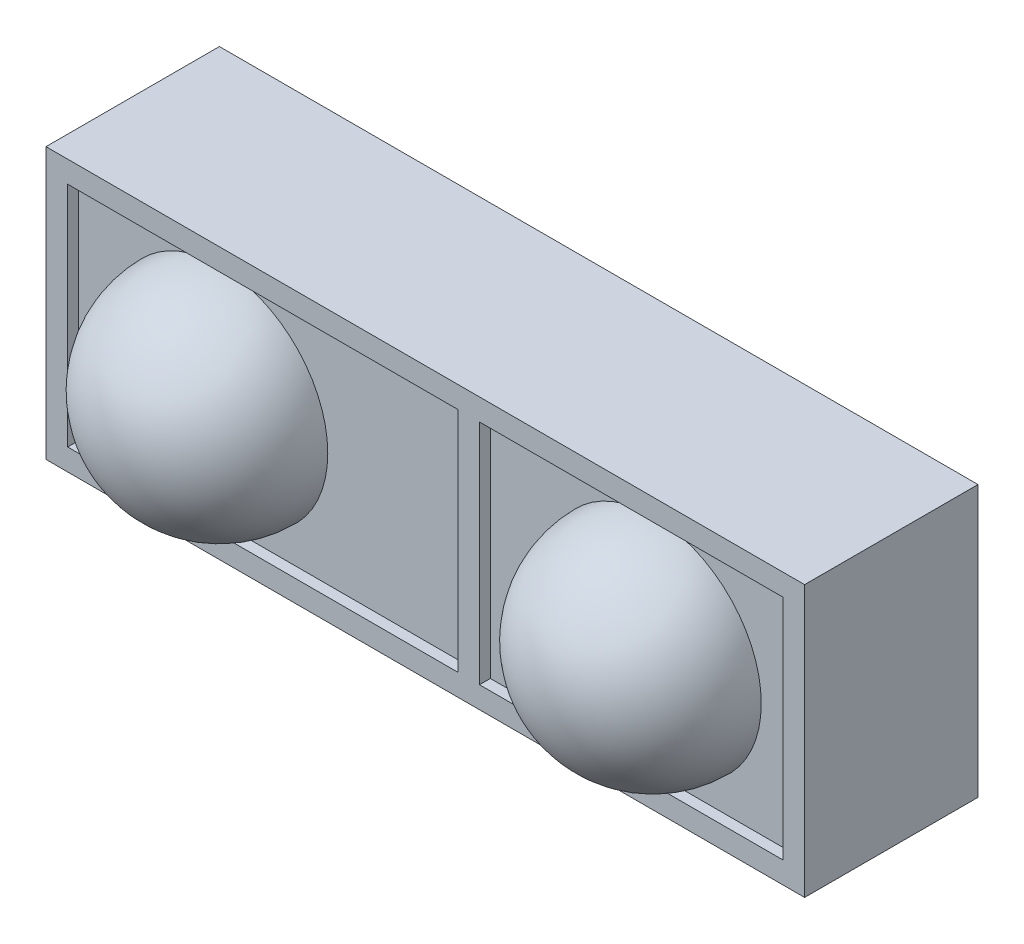
from build123d import *

# Parameters (mm, degrees)
SKETCH1_W       = 7
SKETCH1_H       = 2.5
EXTRUDE1_DEPTH  = 1.5
LPATTERN1_COUNT = 2
LPATTERN1_PITCH = 4
SKETCH3_W       = 7
SKETCH3_H       = 2.5
SKETCH3_W_2     = 3.6
SKETCH3_H_2     = 2.1
SKETCH3_W_3     = 2.8
EXTRUDE2_DEPTH  = 0.1


with BuildPart() as part:
    # Sketch1 → Extrude1 (new body)
    with BuildSketch(Plane.XY):
        Rectangle(SKETCH1_W, SKETCH1_H)
    extrude(amount=EXTRUDE1_DEPTH)

    # Sketch2 → Revolve1 (revolve)
    with BuildSketch(Plane(origin=(0, 0, 0), x_dir=(1, 0, 0), z_dir=(0, 1, 0))):
        with BuildLine():
            Line((2, -2.5), (2, -0.5))
            ThreePointArc((2, -0.5), (3, -1.5), (2, -2.5))
        make_face()
    revolve1 = revolve(axis=Axis((2, 0, 3.037365145), (0, 0, -1)))

    # LPattern1: Revolve1 ×2
    with Locations(*[(-i * LPATTERN1_PITCH, 0, 0) for i in range(1, LPATTERN1_COUNT)]):
        add(revolve1)

    # Sketch3 → Extrude2 (add)
    with BuildSketch(Plane.XY.offset(1.5)):
        Rectangle(SKETCH3_W, SKETCH3_H)
        with Locations((-1.5, 0)):
            Rectangle(SKETCH3_W_2, SKETCH3_H_2, mode=Mode.SUBTRACT)
        with Locations((1.9, 0)):
            Rectangle(SKETCH3_W_3, SKETCH3_H_2, mode=Mode.SUBTRACT)
    extrude(amount=EXTRUDE2_DEPTH)


solid = part.part
